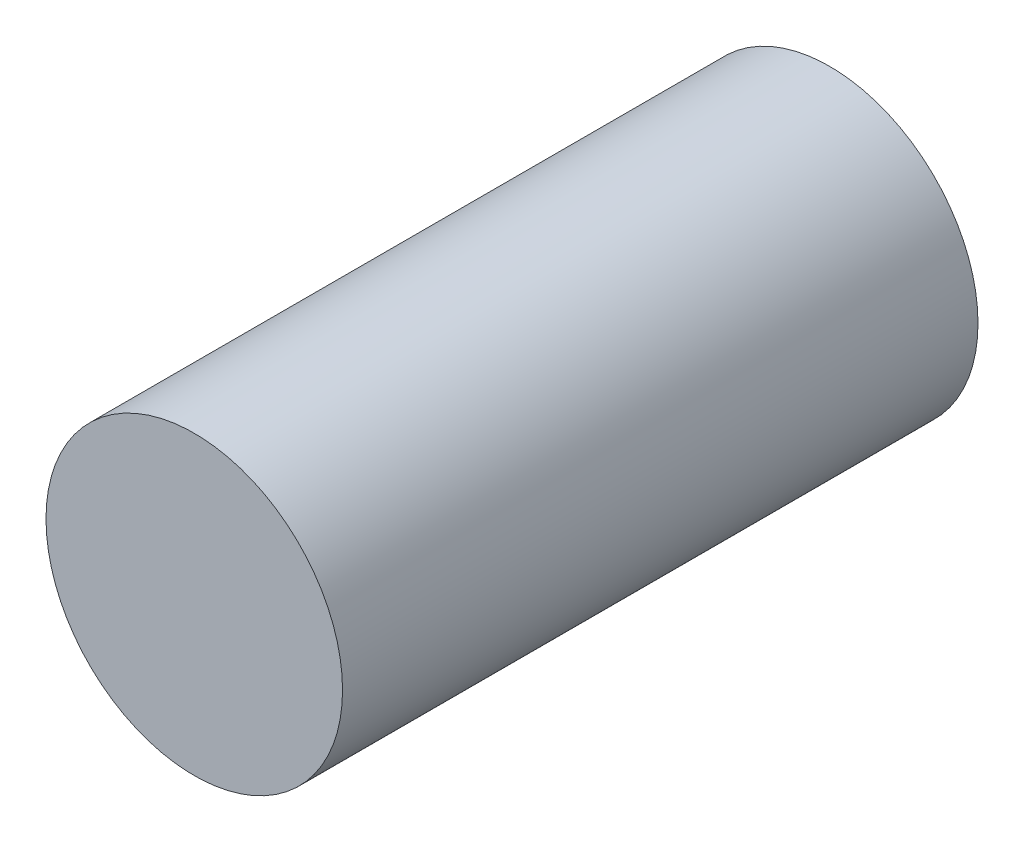
from build123d import *

# Parameters (mm, degrees)
SKETCH1_R           = 3.556
BOSS_EXTRUDE1_DEPTH = 15.24


with BuildPart() as part:
    # Sketch1 → Boss-Extrude1 (new body)
    with BuildSketch(Plane.XY):
        Circle(SKETCH1_R)
    extrude(amount=BOSS_EXTRUDE1_DEPTH)


solid = part.part
